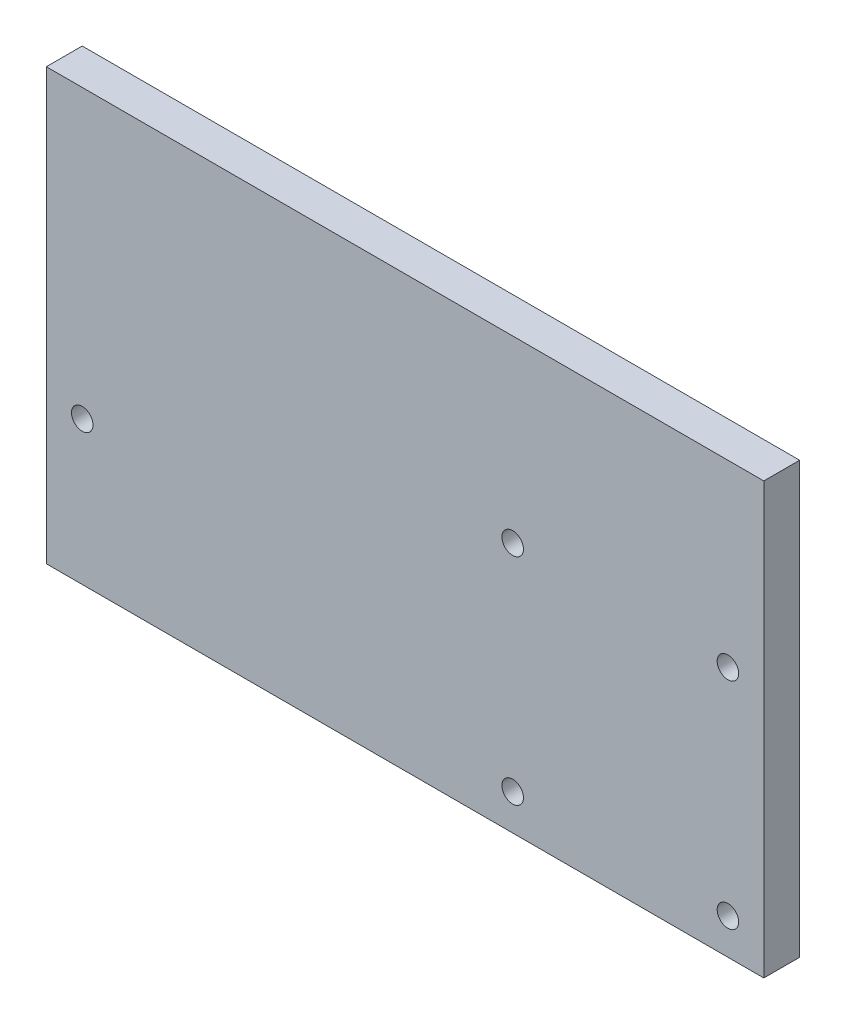
from build123d import *

# Parameters (mm, degrees)
SKETCH1_W           = 127
SKETCH1_H           = 76.2
BOSS_EXTRUDE1_DEPTH = 6.35
CUT_EXTRUDE1_REACH  = 8.35
SKETCH2_R           = 1.905


with BuildPart() as part:
    # Sketch1 → Boss-Extrude1 (new body)
    with BuildSketch(Plane.XY):
        with Locations((63.5, -38.1)):
            Rectangle(SKETCH1_W, SKETCH1_H)
    extrude(amount=BOSS_EXTRUDE1_DEPTH)

    # Sketch2 → Cut-Extrude1 (cut, up to next)
    with BuildSketch(Plane.XY.offset(6.35), mode=Mode.PRIVATE) as cut_extrude1_sk1:
        with Locations((82.55, -31.75)):
            Circle(SKETCH2_R)
    cut_extrude1_tool1 = extrude(cut_extrude1_sk1.sketch, amount=-CUT_EXTRUDE1_REACH, mode=Mode.PRIVATE) & part.part
    add(cut_extrude1_tool1.solids().sort_by_distance((82.55, -31.75, 6.35))[0], mode=Mode.SUBTRACT)
    # Sketch2 → Cut-Extrude1 (cut, up to next)
    with BuildSketch(Plane.XY.offset(6.35), mode=Mode.PRIVATE) as cut_extrude1_sk2:
        with Locations((120.65, -31.75)):
            Circle(SKETCH2_R)
    cut_extrude1_tool2 = extrude(cut_extrude1_sk2.sketch, amount=-CUT_EXTRUDE1_REACH, mode=Mode.PRIVATE) & part.part
    add(cut_extrude1_tool2.solids().sort_by_distance((120.65, -31.75, 6.35))[0], mode=Mode.SUBTRACT)
    # Sketch2 → Cut-Extrude1 (cut, up to next)
    with BuildSketch(Plane.XY.offset(6.35), mode=Mode.PRIVATE) as cut_extrude1_sk3:
        with Locations((82.55, -69.85)):
            Circle(SKETCH2_R)
    cut_extrude1_tool3 = extrude(cut_extrude1_sk3.sketch, amount=-CUT_EXTRUDE1_REACH, mode=Mode.PRIVATE) & part.part
    add(cut_extrude1_tool3.solids().sort_by_distance((82.55, -69.85, 6.35))[0], mode=Mode.SUBTRACT)
    # Sketch2 → Cut-Extrude1 (cut, up to next)
    with BuildSketch(Plane.XY.offset(6.35), mode=Mode.PRIVATE) as cut_extrude1_sk4:
        with Locations((120.65, -69.85)):
            Circle(SKETCH2_R)
    cut_extrude1_tool4 = extrude(cut_extrude1_sk4.sketch, amount=-CUT_EXTRUDE1_REACH, mode=Mode.PRIVATE) & part.part
    add(cut_extrude1_tool4.solids().sort_by_distance((120.65, -69.85, 6.35))[0], mode=Mode.SUBTRACT)
    # Sketch2 → Cut-Extrude1 (cut, up to next)
    with BuildSketch(Plane.XY.offset(6.35), mode=Mode.PRIVATE) as cut_extrude1_sk5:
        with Locations((6.35, -50.8)):
            Circle(SKETCH2_R)
    cut_extrude1_tool5 = extrude(cut_extrude1_sk5.sketch, amount=-CUT_EXTRUDE1_REACH, mode=Mode.PRIVATE) & part.part
    add(cut_extrude1_tool5.solids().sort_by_distance((6.35, -50.8, 6.35))[0], mode=Mode.SUBTRACT)


solid = part.part
